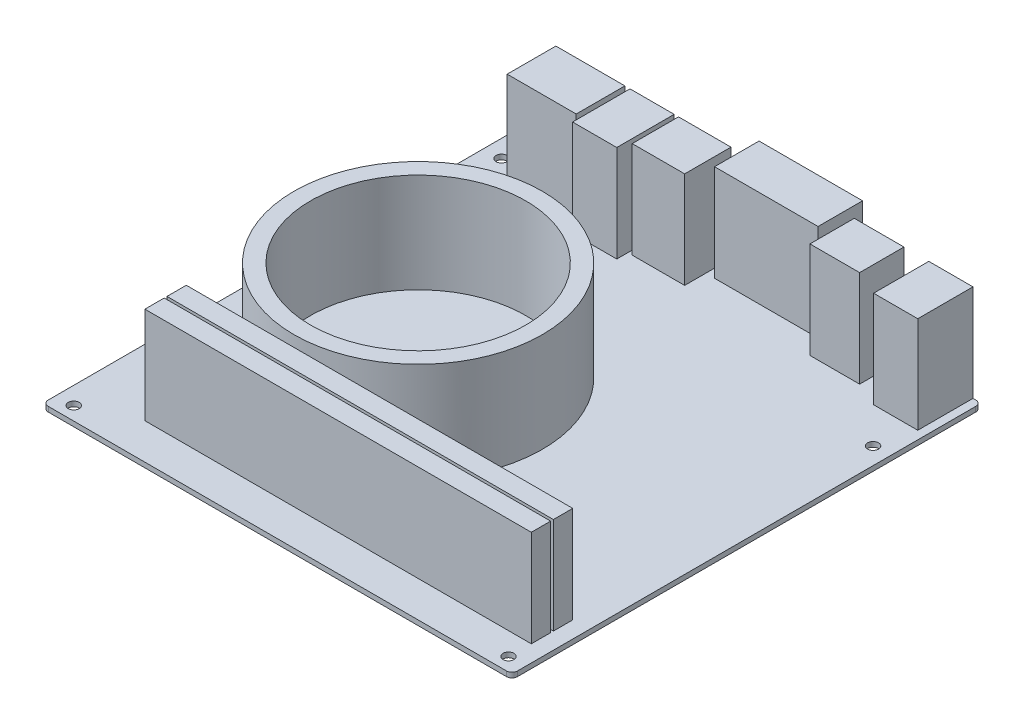
from build123d import *

# Parameters (mm, degrees)
SKETCH1_W           = 170
SKETCH1_H           = 170
BOSS_EXTRUDE1_DEPTH = 1.8
FILLET1_R           = 2
SKETCH2_R           = 1.98
CUT_EXTRUDE1_DEPTH  = 2
SKETCH3_W           = 16
SKETCH3_H           = 20
SKETCH3_W_2         = 37.5
SKETCH3_H_2         = 16.121954722
SKETCH3_W_3         = 18
SKETCH3_H_3         = 16.061076517
SKETCH3_W_4         = 19
SKETCH3_H_4         = 16.780154479
SKETCH3_H_5         = 20.801567196
SKETCH3_W_5         = 25
SKETCH3_H_6         = 17.641885776
BOSS_EXTRUDE2_DEPTH = 35
SKETCH4_W           = 140
SKETCH4_H           = 7
BOSS_EXTRUDE3_DEPTH = 35
LPATTERN1_COUNT     = 2
LPATTERN1_PITCH     = 8
SKETCH5_R           = 45
SKETCH5_R_2         = 39
BOSS_EXTRUDE4_DEPTH = 36


with BuildPart() as part:
    # Sketch1 → Boss-Extrude1 (new body)
    with BuildSketch(Plane(origin=(0, 0, 0), x_dir=(1, 0, 0), z_dir=(0, 1, 0))):
        Rectangle(SKETCH1_W, SKETCH1_H)
    extrude(amount=BOSS_EXTRUDE1_DEPTH)

    # Fillet1
    fillet1_edges = [part.edges().sort_by_distance(p)[0] for p in [
        (-85, 0.9, -85),
        (85, 0.9, -85),
        (85, 0.9, 85),
        (-85, 0.9, 85),
    ]]
    fillet(fillet1_edges, radius=FILLET1_R)

    # Sketch2 → Cut-Extrude1 (cut)
    with BuildSketch(Plane(origin=(0, 1.8, 0), x_dir=(1, 0, 0), z_dir=(0, 1, 0))):
        with Locations((-78.65, 74.84)):
            Circle(SKETCH2_R)
        with Locations((-78.65, -80.1)):
            Circle(SKETCH2_R)
        with Locations((78.83, -80.1)):
            Circle(SKETCH2_R)
        with Locations((78.83, 51.98)):
            Circle(SKETCH2_R)
    extrude(amount=-CUT_EXTRUDE1_DEPTH, mode=Mode.SUBTRACT)

    # Sketch3 → Boss-Extrude2 (add)
    with BuildSketch(Plane(origin=(0, 1.8, 0), x_dir=(1, 0, 0), z_dir=(0, 1, 0))):
        with Locations((74, 75)):
            Rectangle(SKETCH3_W, SKETCH3_H)
        with Locations((16.25, 83.939022639)):
            Rectangle(SKETCH3_W_2, SKETCH3_H_2)
        with Locations((48, 76.969461741)):
            Rectangle(SKETCH3_W_3, SKETCH3_H_3)
        with Locations((-15.17206747, 76.609922761)):
            Rectangle(SKETCH3_W_4, SKETCH3_H_4)
        with Locations((-34.244584998, 74.599216402)):
            Rectangle(SKETCH3_W, SKETCH3_H_5)
        with Locations((-56.603208404, 76.179057112)):
            Rectangle(SKETCH3_W_5, SKETCH3_H_6)
    extrude(amount=BOSS_EXTRUDE2_DEPTH)

    # Sketch4 → Boss-Extrude3 (add)
    with BuildSketch(Plane(origin=(0, 1.8, 0), x_dir=(1, 0, 0), z_dir=(0, 1, 0))):
        with Locations((9, -68.5)):
            Rectangle(SKETCH4_W, SKETCH4_H)
    boss_extrude3 = extrude(amount=BOSS_EXTRUDE3_DEPTH)

    # LPattern1: Boss-Extrude3 ×2
    with Locations(*[(0, 0, -i * LPATTERN1_PITCH) for i in range(1, LPATTERN1_COUNT)]):
        add(boss_extrude3)

    # Sketch5 → Boss-Extrude4 (add)
    with BuildSketch(Plane(origin=(0, 1.8, 0), x_dir=(1, 0, 0), z_dir=(0, 1, 0))):
        with Locations((-25, -9)):
            Circle(SKETCH5_R)
        with Locations((-25, -9)):
            Circle(SKETCH5_R_2, mode=Mode.SUBTRACT)
    extrude(amount=BOSS_EXTRUDE4_DEPTH)


solid = part.part
